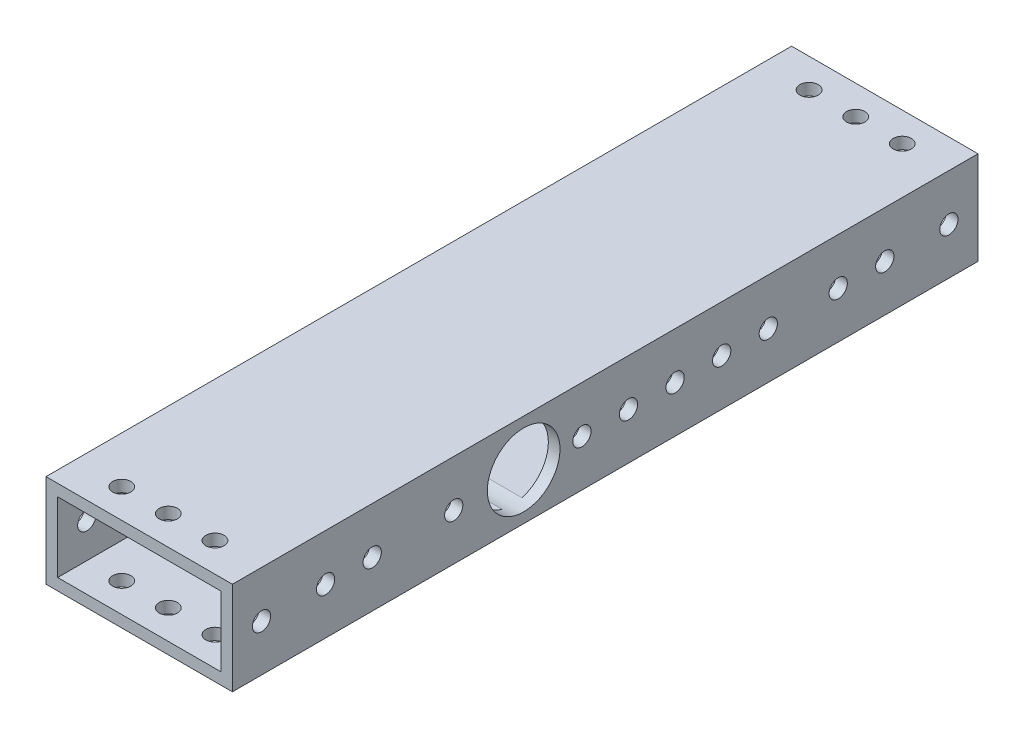
from build123d import *

# Parameters (mm, degrees)
SKETCH1_W           = 50.8
SKETCH1_H           = 25.4
SKETCH1_W_2         = 44.45
SKETCH1_H_2         = 19.05
BOSS_EXTRUDE1_DEPTH = 101.6
SKETCH3_R           = 2.4892
CUT_EXTRUDE2_DEPTH  = 26.4
SKETCH4_R           = 9.906
SKETCH4_R_2         = 2.4892
CUT_EXTRUDE3_DEPTH  = 51.8
SKETCH2_R           = 2.4892
CUT_EXTRUDE1_DEPTH  = 51.8
CUT_EXTRUDE4_REACH  = 27.4
SKETCH5_R           = 2.4892
CUT_EXTRUDE5_REACH  = 52.8
SKETCH7_R           = 2.4892


with BuildPart() as part:
    # Sketch1 → Boss-Extrude1 (new body, symmetric)
    with BuildSketch(Plane.XY):
        Rectangle(SKETCH1_W, SKETCH1_H)
        Rectangle(SKETCH1_W_2, SKETCH1_H_2, mode=Mode.SUBTRACT)
    extrude(amount=BOSS_EXTRUDE1_DEPTH, both=True)

    # Sketch3 → Cut-Extrude2 (cut, through all)
    with BuildSketch(Plane(origin=(0, 12.7, 0), x_dir=(1, 0, 0), z_dir=(0, 1, 0))):
        with Locations((-12.7, -93.6625)):
            Circle(SKETCH3_R)
        with Locations((0, -93.6625)):
            Circle(SKETCH3_R)
        with Locations((12.7, -93.6625)):
            Circle(SKETCH3_R)
        with Locations((12.7, 93.6625)):
            Circle(SKETCH3_R)
        with Locations((0, 93.6625)):
            Circle(SKETCH3_R)
        with Locations((-12.7, 93.6625)):
            Circle(SKETCH3_R)
    extrude(amount=-CUT_EXTRUDE2_DEPTH, mode=Mode.SUBTRACT)

    # Sketch4 → Cut-Extrude3 (cut, through all)
    with BuildSketch(Plane(origin=(25.4, 0, 0), x_dir=(0, 0, -1), z_dir=(1, 0, 0))):
        with Locations((-22.225, 0)):
            Circle(SKETCH4_R)
        with Locations((31.75, 0)):
            Circle(SKETCH4_R_2)
        with Locations((19.05, 0)):
            Circle(SKETCH4_R_2)
    extrude(amount=-CUT_EXTRUDE3_DEPTH, mode=Mode.SUBTRACT)

    # Sketch2 → Cut-Extrude1 (cut, through all)
    with BuildSketch(Plane(origin=(25.4, 0, 0), x_dir=(0, 0, -1), z_dir=(1, 0, 0))):
        with Locations((-93.6625, 0)):
            Circle(SKETCH2_R)
        with Locations((93.6625, 0)):
            Circle(SKETCH2_R)
        with Locations((-76.2, 0)):
            Circle(SKETCH2_R)
        with Locations((-63.5, 0)):
            Circle(SKETCH2_R)
        with Locations((63.5, 0)):
            Circle(SKETCH2_R)
        with Locations((76.2, 0)):
            Circle(SKETCH2_R)
    extrude(amount=-CUT_EXTRUDE1_DEPTH, mode=Mode.SUBTRACT)

    # Sketch5 → Cut-Extrude4 (cut, up to next)
    with BuildSketch(Plane.XZ.offset(12.7), mode=Mode.PRIVATE) as cut_extrude4_sk1:
        with Locations((-3.175, 66.675)):
            Circle(SKETCH5_R)
    cut_extrude4_tool1 = extrude(cut_extrude4_sk1.sketch, amount=-CUT_EXTRUDE4_REACH, mode=Mode.PRIVATE) & part.part
    add(cut_extrude4_tool1.solids().sort_by_distance((-3.175, -12.7, 66.675))[0], mode=Mode.SUBTRACT)
    # Sketch5 → Cut-Extrude4 (cut, up to next)
    with BuildSketch(Plane.XZ.offset(12.7), mode=Mode.PRIVATE) as cut_extrude4_sk2:
        with Locations((-15.875, 66.675)):
            Circle(SKETCH5_R)
    cut_extrude4_tool2 = extrude(cut_extrude4_sk2.sketch, amount=-CUT_EXTRUDE4_REACH, mode=Mode.PRIVATE) & part.part
    add(cut_extrude4_tool2.solids().sort_by_distance((-15.875, -12.7, 66.675))[0], mode=Mode.SUBTRACT)
    # Sketch5 → Cut-Extrude4 (cut, up to next)
    with BuildSketch(Plane.XZ.offset(12.7), mode=Mode.PRIVATE) as cut_extrude4_sk3:
        with Locations((-15.875, 53.975)):
            Circle(SKETCH5_R)
    cut_extrude4_tool3 = extrude(cut_extrude4_sk3.sketch, amount=-CUT_EXTRUDE4_REACH, mode=Mode.PRIVATE) & part.part
    add(cut_extrude4_tool3.solids().sort_by_distance((-15.875, -12.7, 53.975))[0], mode=Mode.SUBTRACT)
    # Sketch5 → Cut-Extrude4 (cut, up to next)
    with BuildSketch(Plane.XZ.offset(12.7), mode=Mode.PRIVATE) as cut_extrude4_sk4:
        with Locations((-3.175, 53.975)):
            Circle(SKETCH5_R)
    cut_extrude4_tool4 = extrude(cut_extrude4_sk4.sketch, amount=-CUT_EXTRUDE4_REACH, mode=Mode.PRIVATE) & part.part
    add(cut_extrude4_tool4.solids().sort_by_distance((-3.175, -12.7, 53.975))[0], mode=Mode.SUBTRACT)
    # Sketch5 → Cut-Extrude4 (cut, up to next)
    with BuildSketch(Plane.XZ.offset(12.7), mode=Mode.PRIVATE) as cut_extrude4_sk5:
        with Locations((-3.175, -9.525)):
            Circle(SKETCH5_R)
    cut_extrude4_tool5 = extrude(cut_extrude4_sk5.sketch, amount=-CUT_EXTRUDE4_REACH, mode=Mode.PRIVATE) & part.part
    add(cut_extrude4_tool5.solids().sort_by_distance((-3.175, -12.7, -9.525))[0], mode=Mode.SUBTRACT)
    # Sketch5 → Cut-Extrude4 (cut, up to next)
    with BuildSketch(Plane.XZ.offset(12.7), mode=Mode.PRIVATE) as cut_extrude4_sk6:
        with Locations((-15.875, -9.525)):
            Circle(SKETCH5_R)
    cut_extrude4_tool6 = extrude(cut_extrude4_sk6.sketch, amount=-CUT_EXTRUDE4_REACH, mode=Mode.PRIVATE) & part.part
    add(cut_extrude4_tool6.solids().sort_by_distance((-15.875, -12.7, -9.525))[0], mode=Mode.SUBTRACT)
    # Sketch5 → Cut-Extrude4 (cut, up to next)
    with BuildSketch(Plane.XZ.offset(12.7), mode=Mode.PRIVATE) as cut_extrude4_sk7:
        with Locations((-15.875, -22.225)):
            Circle(SKETCH5_R)
    cut_extrude4_tool7 = extrude(cut_extrude4_sk7.sketch, amount=-CUT_EXTRUDE4_REACH, mode=Mode.PRIVATE) & part.part
    add(cut_extrude4_tool7.solids().sort_by_distance((-15.875, -12.7, -22.225))[0], mode=Mode.SUBTRACT)
    # Sketch5 → Cut-Extrude4 (cut, up to next)
    with BuildSketch(Plane.XZ.offset(12.7), mode=Mode.PRIVATE) as cut_extrude4_sk8:
        with Locations((-3.175, -22.225)):
            Circle(SKETCH5_R)
    cut_extrude4_tool8 = extrude(cut_extrude4_sk8.sketch, amount=-CUT_EXTRUDE4_REACH, mode=Mode.PRIVATE) & part.part
    add(cut_extrude4_tool8.solids().sort_by_distance((-3.175, -12.7, -22.225))[0], mode=Mode.SUBTRACT)

    # Sketch7 → Cut-Extrude5 (cut, up to next)
    with BuildSketch(Plane(origin=(25.4, 0, 0), x_dir=(0, 0, -1), z_dir=(1, 0, 0)), mode=Mode.PRIVATE) as cut_extrude5_sk1:
        with Locations((44.45, 0)):
            Circle(SKETCH7_R)
    cut_extrude5_tool1 = extrude(cut_extrude5_sk1.sketch, amount=-CUT_EXTRUDE5_REACH, mode=Mode.PRIVATE) & part.part
    add(cut_extrude5_tool1.solids().sort_by_distance((25.4, 0, -44.45))[0], mode=Mode.SUBTRACT)
    # Sketch7 → Cut-Extrude5 (cut, up to next)
    with BuildSketch(Plane(origin=(25.4, 0, 0), x_dir=(0, 0, -1), z_dir=(1, 0, 0)), mode=Mode.PRIVATE) as cut_extrude5_sk2:
        with Locations((6.35, 0)):
            Circle(SKETCH7_R)
    cut_extrude5_tool2 = extrude(cut_extrude5_sk2.sketch, amount=-CUT_EXTRUDE5_REACH, mode=Mode.PRIVATE) & part.part
    add(cut_extrude5_tool2.solids().sort_by_distance((25.4, 0, -6.35))[0], mode=Mode.SUBTRACT)
    # Sketch7 → Cut-Extrude5 (cut, up to next)
    with BuildSketch(Plane(origin=(25.4, 0, 0), x_dir=(0, 0, -1), z_dir=(1, 0, 0)), mode=Mode.PRIVATE) as cut_extrude5_sk3:
        with Locations((-6.35, 0)):
            Circle(SKETCH7_R)
    cut_extrude5_tool3 = extrude(cut_extrude5_sk3.sketch, amount=-CUT_EXTRUDE5_REACH, mode=Mode.PRIVATE) & part.part
    add(cut_extrude5_tool3.solids().sort_by_distance((25.4, 0, 6.35))[0], mode=Mode.SUBTRACT)
    # Sketch7 → Cut-Extrude5 (cut, up to next)
    with BuildSketch(Plane(origin=(25.4, 0, 0), x_dir=(0, 0, -1), z_dir=(1, 0, 0)), mode=Mode.PRIVATE) as cut_extrude5_sk4:
        with Locations((-41.275, 0)):
            Circle(SKETCH7_R)
    cut_extrude5_tool4 = extrude(cut_extrude5_sk4.sketch, amount=-CUT_EXTRUDE5_REACH, mode=Mode.PRIVATE) & part.part
    add(cut_extrude5_tool4.solids().sort_by_distance((25.4, 0, 41.275))[0], mode=Mode.SUBTRACT)


solid = part.part
